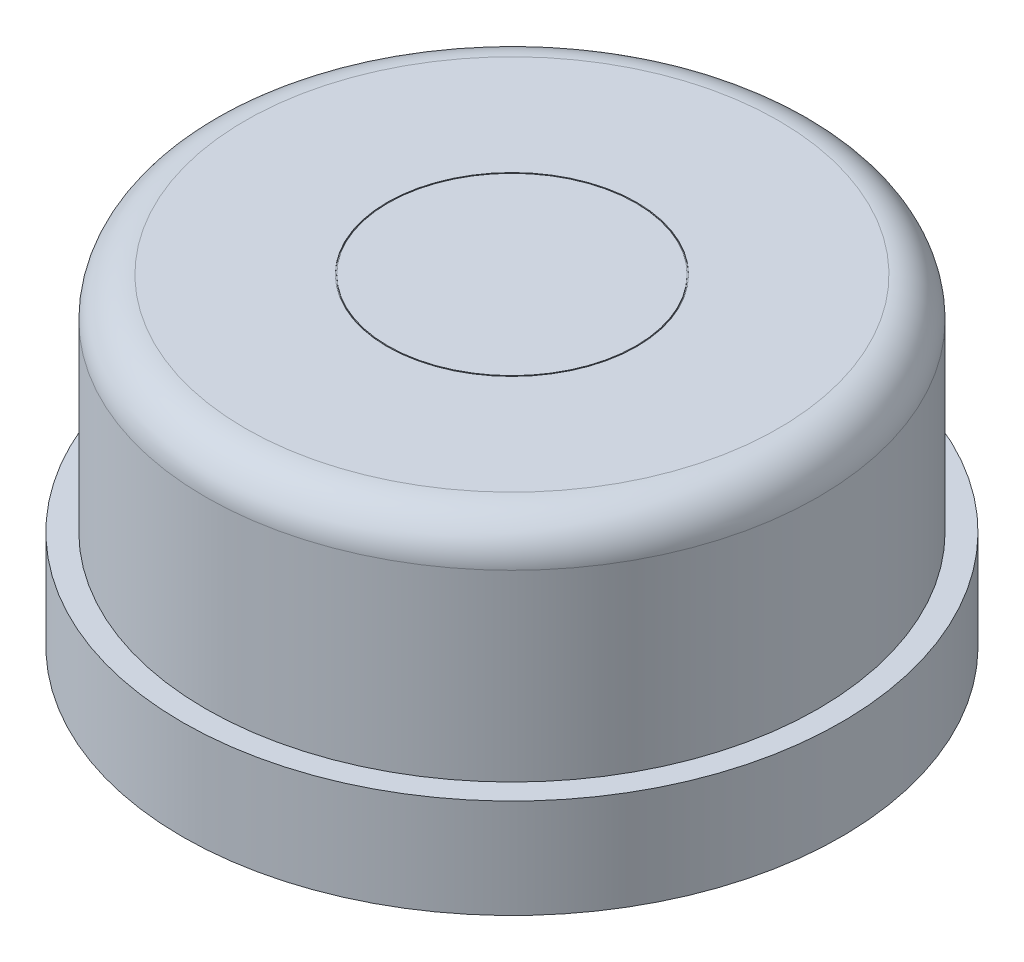
from build123d import *

# Parameters (mm, degrees)
SKETCH1_R               = 8.4455
BOSS_EXTRUDE1_DEPTH     = 2.54
SKETCH2_R               = 7.8486
BOSS_EXTRUDE2_DEPTH     = 8.255
FILLET1_R               = 1.016
SKETCH3_R               = 3.2004
SKETCH3_R_2             = 3.175
CUT_EXTRUDE_THIN1_DEPTH = 0.0254


with BuildPart() as part:
    # Sketch1 → Boss-Extrude1 (new body)
    with BuildSketch(Plane(origin=(0, 0, 0), x_dir=(1, 0, 0), z_dir=(0, 1, 0))):
        Circle(SKETCH1_R)
    extrude(amount=BOSS_EXTRUDE1_DEPTH)

    # Sketch2 → Boss-Extrude2 (add)
    with BuildSketch(Plane(origin=(0, 0, 0), x_dir=(1, 0, 0), z_dir=(0, 1, 0))):
        Circle(SKETCH2_R)
    extrude(amount=BOSS_EXTRUDE2_DEPTH)

    # Fillet1
    fillet1_edges = [part.edges().sort_by_distance(p)[0] for p in [
        (-7.8486, 8.255, 0),
    ]]
    fillet(fillet1_edges, radius=FILLET1_R)

    # Sketch3 → Cut-Extrude-Thin1 (cut)
    with BuildSketch(Plane(origin=(0, 8.255, 0), x_dir=(1, 0, 0), z_dir=(0, 1, 0))):
        Circle(SKETCH3_R)
        Circle(SKETCH3_R_2, mode=Mode.SUBTRACT)
    extrude(amount=-CUT_EXTRUDE_THIN1_DEPTH, mode=Mode.SUBTRACT)


solid = part.part
